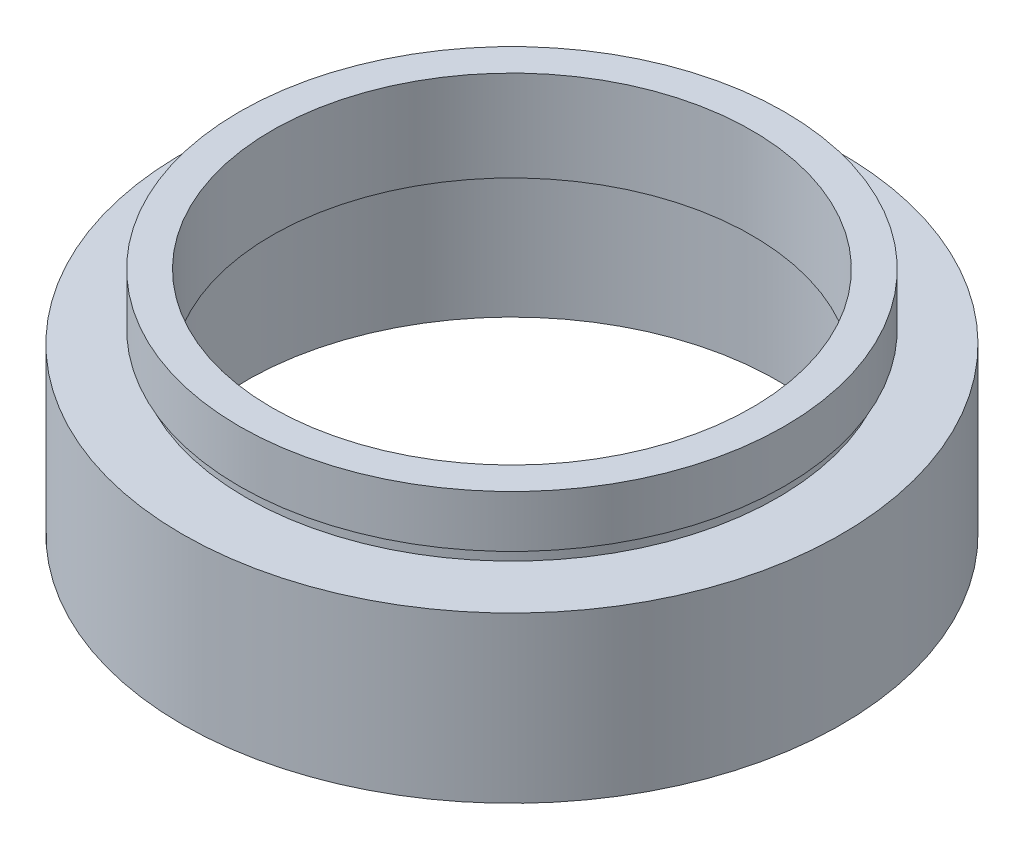
from build123d import *


with BuildPart() as part:
    # 草图1 → 旋转1 (revolve)
    with BuildSketch(Plane.XY, mode=Mode.PRIVATE) as revolve_1_sk:
        Polygon((18.5, 17.7), (21, 17.7), (21, 13.7), (20.5, 13.7), (20.5, 12.7), (25.4, 12.7), (25.4, 0), (20.5, 0), (20.5, 9.7), (21.1, 9.7), (21.1, 10.7), (18.5, 10.7), align=None)
    revolve(revolve_1_sk.sketch.rotate(Axis((0, 161.376166943, 0), (0, -1, 0)), 90), axis=Axis((0, 161.376166943, 0), (0, -1, 0)))  # turned: the seam where the file's is


solid = part.part
